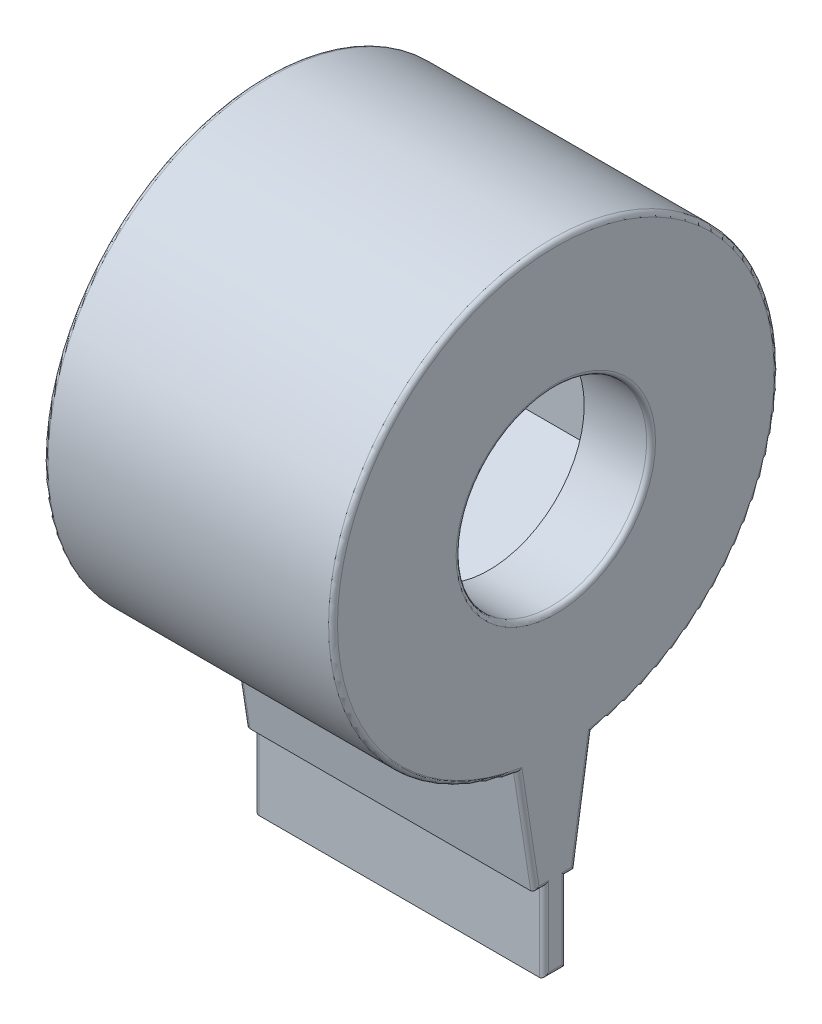
from build123d import *

# Parameters (mm, degrees)
BOSS_EXTRUDE1_DEPTH      = 10
BOSS_EXTRUDE1_DEPTH_BACK = 3
SKETCH3_R                = 10
BOSS_EXTRUDE2_DEPTH      = 7
SKETCH4_R                = 10
SKETCH4_R_2              = 4.275866884
BOSS_EXTRUDE3_DEPTH      = 3
BOSS_EXTRUDE5_START      = 3
SKETCH5_R                = 10
SKETCH5_R_2              = 4.275866884
BOSS_EXTRUDE5_DEPTH      = 3
FILLET1_R                = 0.2


with BuildPart() as part:
    # Sketch1 → Boss-Extrude1 (new, two sides: drawn at the far end of the back side and taken through both)
    with BuildSketch(Plane(origin=(0, 0, 0), x_dir=(0, 0, -1), z_dir=(1, 0, 0)).offset(-BOSS_EXTRUDE1_DEPTH_BACK)):
        Polygon((-0.9, 5), (-1.9, 11.5), (1.9, 11.5), (0.9, 5), (0.49863691, 5), (0.49863691, 1.42579855), (-0.49863691, 1.42579855), (-0.49863691, 5), align=None)
    extrude(amount=BOSS_EXTRUDE1_DEPTH + BOSS_EXTRUDE1_DEPTH_BACK)

    # Sketch4 → Boss-Extrude3 (add)
    with BuildSketch(Plane(origin=(7, 0, 0), x_dir=(0, 0, -1), z_dir=(1, 0, 0))):
        with Locations((0.02673714, 19.876573363)):
            Circle(SKETCH4_R)
        with Locations((0.02673714, 19.876573363)):
            Circle(SKETCH4_R_2, mode=Mode.SUBTRACT)
    extrude(amount=BOSS_EXTRUDE3_DEPTH)

    # Sketch5 → Boss-Extrude5 (add)
    with BuildSketch(Plane.ZY.offset(BOSS_EXTRUDE5_START)):
        with Locations((-0.02673714, 19.876573363)):
            Circle(SKETCH5_R)
        with Locations((-0.02673714, 19.876573363)):
            Circle(SKETCH5_R_2, mode=Mode.SUBTRACT)
    extrude(amount=-BOSS_EXTRUDE5_DEPTH)

    # Fillet1
    fillet1_edges = [part.edges().sort_by_distance(p)[0] for p in [
        (10, 19.876573363, 4.249129744),
        (10, 5, -0.699318455),
        (10, 3.212899275, -0.49863691),
        (10, 1.42579855, 0),
        (10, 3.212899275, 0.49863691),
        (10, 5, 0.699318455),
        (10, 7.511010819, 1.286309357),
        (10, 29.876534594, -0.054582443),
        (10, 7.506355338, -1.285593129),
        (-3, 19.876573363, -4.302604024),
        (-3, 5, 0.699318455),
        (-3, 3.212899275, 0.49863691),
        (-3, 1.42579855, 0),
        (-3, 3.212899275, -0.49863691),
        (-3, 5, -0.699318455),
        (-3, 7.506355338, -1.285593129),
        (-3, 29.876534594, -0.054582443),
        (-3, 7.511010819, 1.286309357),
    ]]
    fillet(fillet1_edges, radius=FILLET1_R)


with BuildPart() as body_2:
    # Sketch3 → Boss-Extrude2 (new body)
    with BuildSketch(Plane(origin=(0, 0, 0), x_dir=(0, 0, -1), z_dir=(1, 0, 0))):
        with Locations((0.02673714, 19.876573363)):
            Circle(SKETCH3_R)
        Polygon((-6.765606496, 23.75539232), (-6.765606496, 15.997772407), (-0.015606496, 12.10065809), (6.744933656, 15.979459046), (6.744933656, 23.77368768), (0.02673714, 27.652440247), align=None, mode=Mode.SUBTRACT)
    extrude(amount=BOSS_EXTRUDE2_DEPTH)

    # Combine1: union part
    add(part.part)


solid = body_2.part
